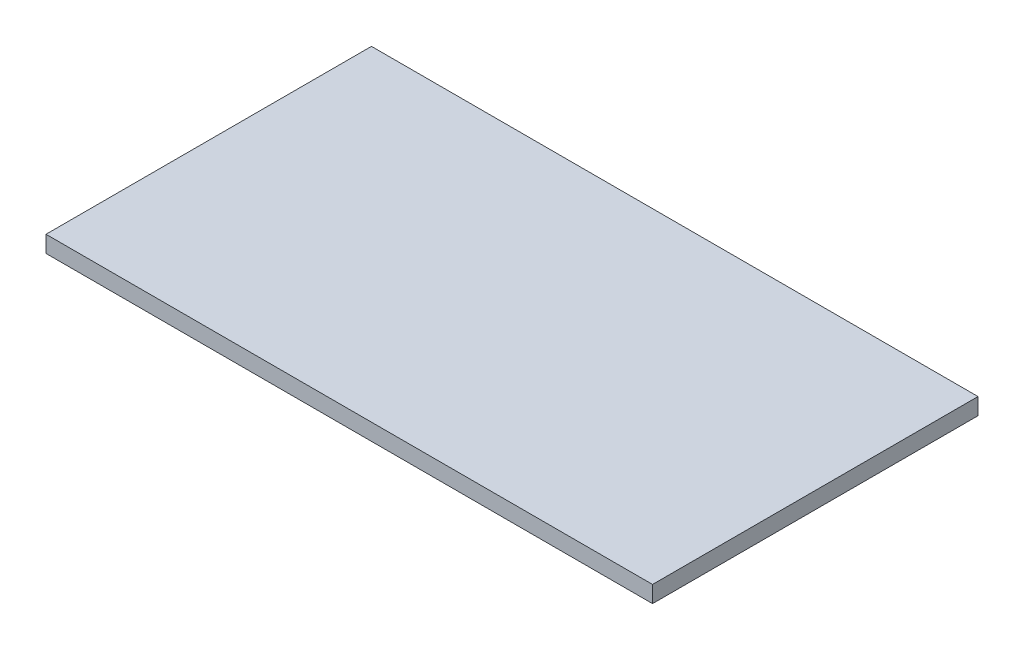
from build123d import *

# Parameters (mm, degrees)
SKETCH1_W           = 520.7
SKETCH1_H           = 279.4
BOSS_EXTRUDE1_DEPTH = 14.2875


with BuildPart() as part:
    # Sketch1 → Boss-Extrude1 (new body)
    with BuildSketch(Plane(origin=(0, 0, 0), x_dir=(1, 0, 0), z_dir=(0, 1, 0))):
        with Locations((53.701436031, -33.656657963)):
            Rectangle(SKETCH1_W, SKETCH1_H)
    extrude(amount=BOSS_EXTRUDE1_DEPTH)


solid = part.part
